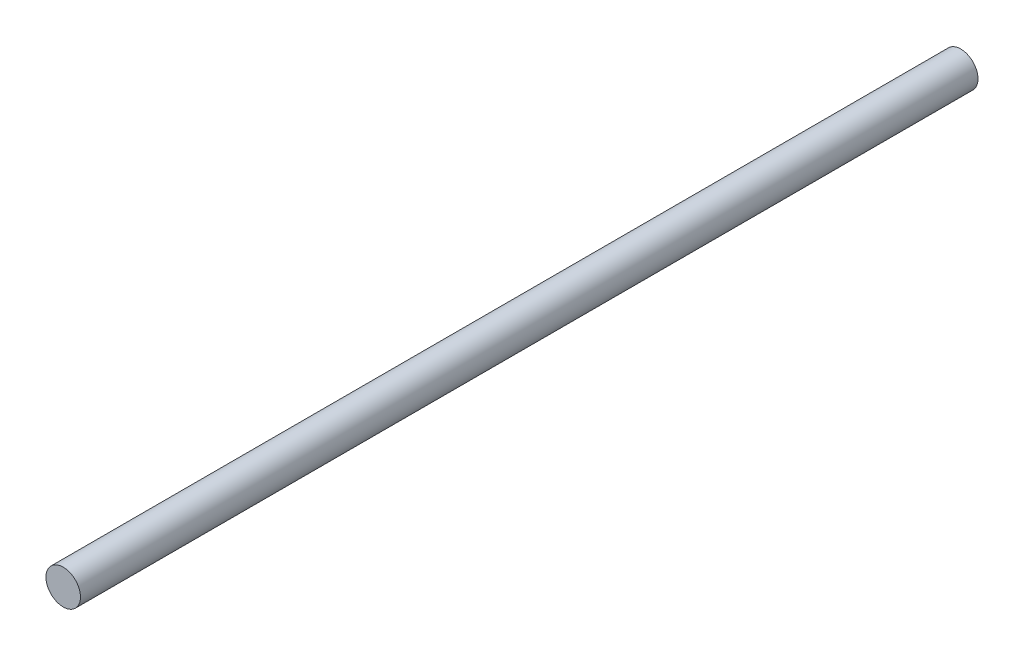
from build123d import *

# Parameters (mm, degrees)
SKETCH1_R           = 6.35
BOSS_EXTRUDE1_DEPTH = 330.2


with BuildPart() as part:
    # Sketch1 → Boss-Extrude1 (new body)
    with BuildSketch(Plane.XY):
        Circle(SKETCH1_R)
    extrude(amount=BOSS_EXTRUDE1_DEPTH)


solid = part.part
